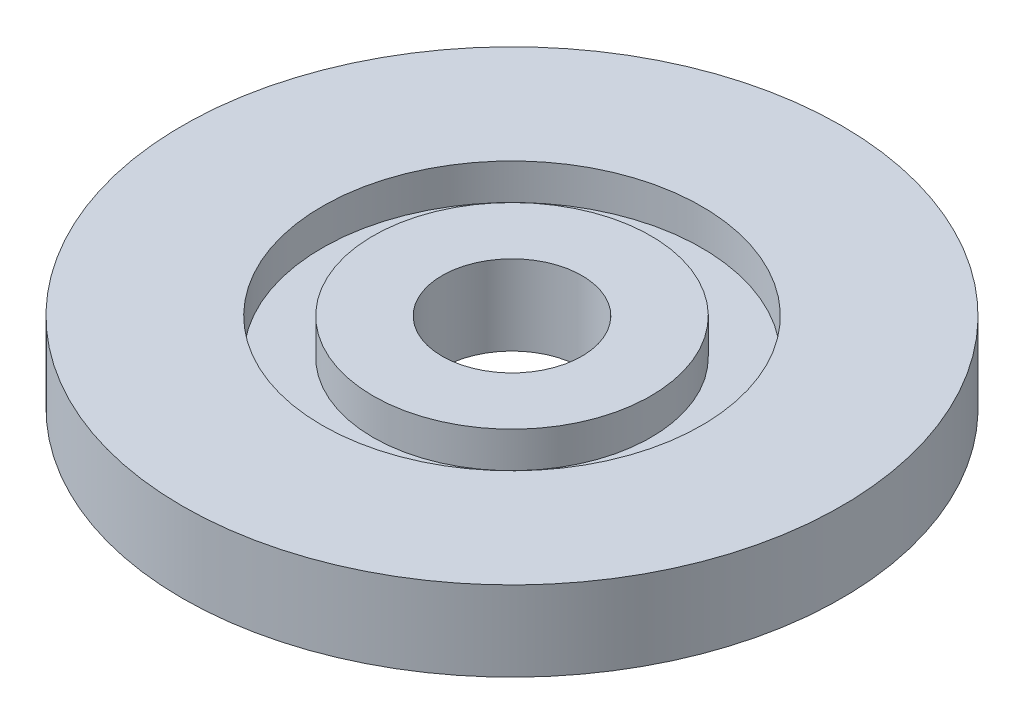
from build123d import *

# Parameters (mm, degrees)
SKETCH1_R           = 82.5
BOSS_EXTRUDE1_DEPTH = 20
SKETCH2_R           = 17.5
CUT_EXTRUDE1_DEPTH  = 20
SKETCH3_R           = 47.5
SKETCH3_R_2         = 34.75
CUT_EXTRUDE2_DEPTH  = 9
SKETCH4_R           = 2.5
CUT_EXTRUDE3_DEPTH  = 13


with BuildPart() as part:
    # Sketch1 → Boss-Extrude1 (new body)
    with BuildSketch(Plane(origin=(0, 0, 0), x_dir=(1, 0, 0), z_dir=(0, 1, 0))):
        Circle(SKETCH1_R)
    extrude(amount=BOSS_EXTRUDE1_DEPTH)

    # Sketch2 → Cut-Extrude1 (cut)
    with BuildSketch(Plane(origin=(0, 20, 0), x_dir=(1, 0, 0), z_dir=(0, 1, 0))):
        Circle(SKETCH2_R)
    extrude(amount=-CUT_EXTRUDE1_DEPTH, mode=Mode.SUBTRACT)

    # Sketch3 → Cut-Extrude2 (cut)
    with BuildSketch(Plane(origin=(0, 20, 0), x_dir=(1, 0, 0), z_dir=(0, 1, 0))):
        Circle(SKETCH3_R)
        Circle(SKETCH3_R_2, mode=Mode.SUBTRACT)
    extrude(amount=-CUT_EXTRUDE2_DEPTH, mode=Mode.SUBTRACT)

    # Sketch4 → Cut-Extrude3 (cut)
    with BuildSketch(Plane.XZ):
        with Locations((0, 70)):
            Circle(SKETCH4_R)
        with Locations((60.621778265, 35)):
            Circle(SKETCH4_R)
        with Locations((60.621778265, -35)):
            Circle(SKETCH4_R)
        with Locations((0, -70)):
            Circle(SKETCH4_R)
        with Locations((-60.621778265, -35)):
            Circle(SKETCH4_R)
        with Locations((-60.621778265, 35)):
            Circle(SKETCH4_R)
    extrude(amount=-CUT_EXTRUDE3_DEPTH, mode=Mode.SUBTRACT)


solid = part.part
